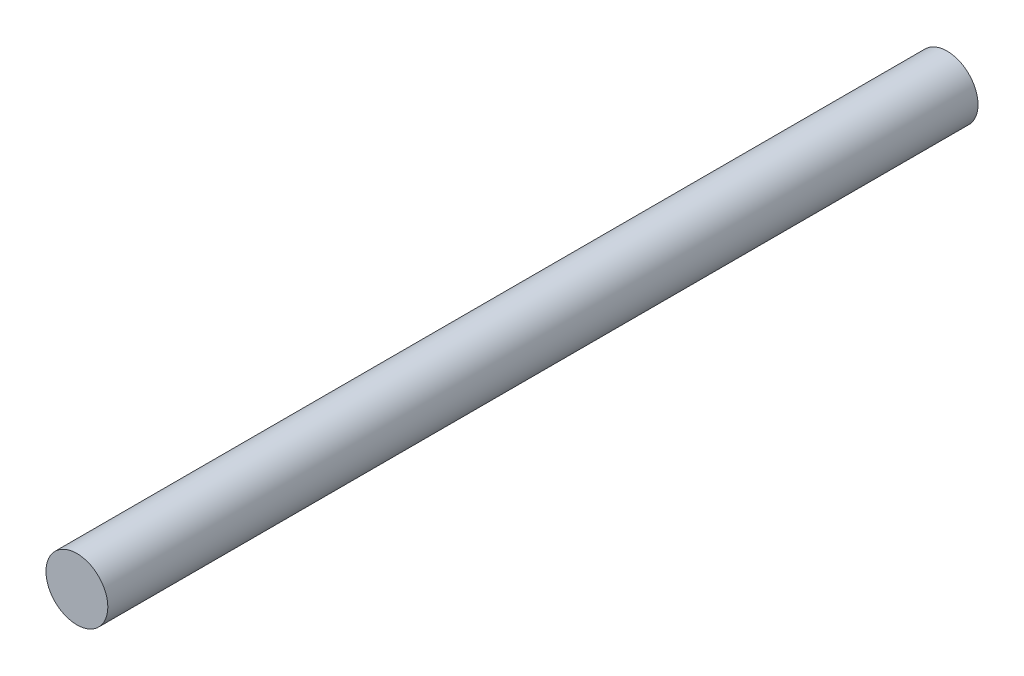
from build123d import *

# Parameters (mm, degrees)
SKETCH1_R           = 1.6
BOSS_EXTRUDE1_DEPTH = 45


with BuildPart() as part:
    # Sketch1 → Boss-Extrude1 (new body)
    with BuildSketch(Plane.XY):
        Circle(SKETCH1_R)
    extrude(amount=BOSS_EXTRUDE1_DEPTH)


solid = part.part
